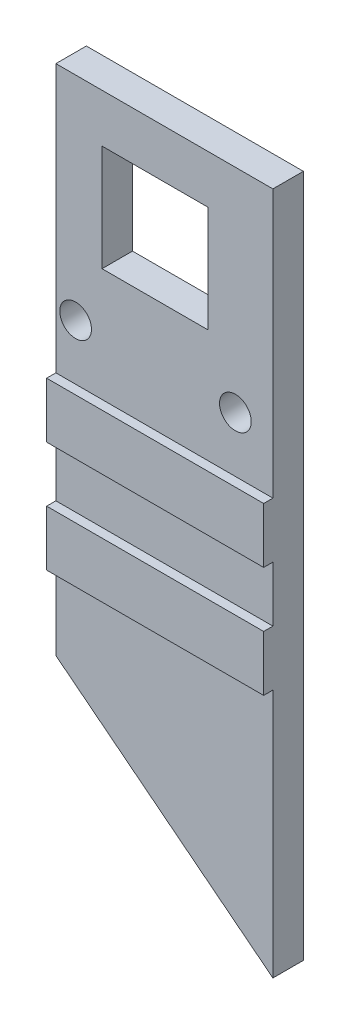
from build123d import *

# Parameters (mm, degrees)
SKETCH_1_W          = 30.50790567
SKETCH_1_H          = 76
SKETCH_1_R          = 1.716069694
SKETCH_1_W_2        = 11.5
SKETCH_1_H_2        = 11.5
SKETCH_1_W_3        = 24.50790567
SKETCH_1_H_3        = 19
EXTRUDE_1_DEPTH     = 3.3
SKETCH_2_W          = 30.50790567
SKETCH_2_H          = 6
EXTRUDE_2_DEPTH     = 1
EXTRUDE_3_DEPTH     = 3.3
CUT_EXTRUDE_1_DEPTH = 3.3
EXTRUDE_5_DEPTH     = 3.3
SKETCH_6_W          = 30.50790567
SKETCH_6_H          = 24.027073242
EXTRUDE_6_DEPTH     = 3.3
CUT_EXTRUDE_3_DEPTH = 3.3
SKETCH_8_W          = 4.466233575
SKETCH_8_H          = 58.072220184
SKETCH_8_W_2        = 2.541672095
SKETCH_8_H_2        = 76
CUT_EXTRUDE_4_DEPTH = 11.3


with BuildPart() as part:
    # 草圖1 → 填料-伸長1 (new body)
    with BuildSketch(Plane.XY):
        with Locations((0, -4.833822083)):
            Rectangle(SKETCH_1_W, SKETCH_1_H)
        with Locations((-8.65, 10.166177917)):
            Circle(SKETCH_1_R, mode=Mode.SUBTRACT)
        with Locations((-0.03771926, 22.181861337)):
            Rectangle(SKETCH_1_W_2, SKETCH_1_H_2, mode=Mode.SUBTRACT)
        with Locations((8.65, 10.166177917)):
            Circle(SKETCH_1_R, mode=Mode.SUBTRACT)
        with Locations((0, -30.333822083)):
            Rectangle(SKETCH_1_W_3, SKETCH_1_H_3, mode=Mode.SUBTRACT)
    extrude(amount=EXTRUDE_1_DEPTH)

    # 草圖2 → 填料-伸長2 (add)
    with BuildSketch(Plane.XY.offset(3.3)):
        with Locations((0, 1.166177917)):
            Rectangle(SKETCH_2_W, SKETCH_2_H)
        with Locations((0, -10.833822083)):
            Rectangle(SKETCH_2_W, SKETCH_2_H)
    extrude(amount=EXTRUDE_2_DEPTH)

    # 草圖3 → 填料-伸長3 (add)
    with BuildSketch(Plane.XY):
        Polygon((15.253952835, -42.833822083), (-15.253952835, -18.474060109), (15.253952835, -18.474060109), align=None)
    extrude(amount=EXTRUDE_3_DEPTH)

    # 草圖4 → 除料-伸長1 (cut)
    with BuildSketch(Plane.XY.offset(3.3)):
        Polygon((15.253952835, -42.833822083), (-15.253952835, -18.806748841), (-15.253952835, -42.833822083), align=None)
    extrude(amount=-CUT_EXTRUDE_1_DEPTH, mode=Mode.SUBTRACT)

    # 草圖5 → 填料-伸長5 (add)
    with BuildSketch(Plane.XY.offset(3.3)):
        Polygon((15.253952835, -42.833822083), (-15.253952835, -42.833822083), (-15.253952835, -18.806748841), align=None)
    extrude(amount=-EXTRUDE_5_DEPTH)

    # 草圖6 → 填料-伸長6 (add)
    with BuildSketch(Plane.XY.offset(3.3)):
        with Locations((0, -30.820285462)):
            Rectangle(SKETCH_6_W, SKETCH_6_H)
    extrude(amount=-EXTRUDE_6_DEPTH)

    # 草圖7 → 除料-伸長3 (cut)
    with BuildSketch(Plane.XY.offset(3.3)):
        Polygon((-15.253952835, -18.833822083), (15.253952835, -42.833822083), (-15.253952835, -42.833822083), align=None)
    extrude(amount=-CUT_EXTRUDE_3_DEPTH, mode=Mode.SUBTRACT)

    # 草圖8 → 除料-伸長4 (cut)
    with BuildSketch(Plane.XY.offset(4.3)):
        with Locations((-13.020836048, 4.130067825)):
            Rectangle(SKETCH_8_W, SKETCH_8_H)
        with Locations((13.983116788, -4.833822083)):
            Rectangle(SKETCH_8_W_2, SKETCH_8_H_2)
    extrude(amount=-CUT_EXTRUDE_4_DEPTH, mode=Mode.SUBTRACT)


solid = part.part
